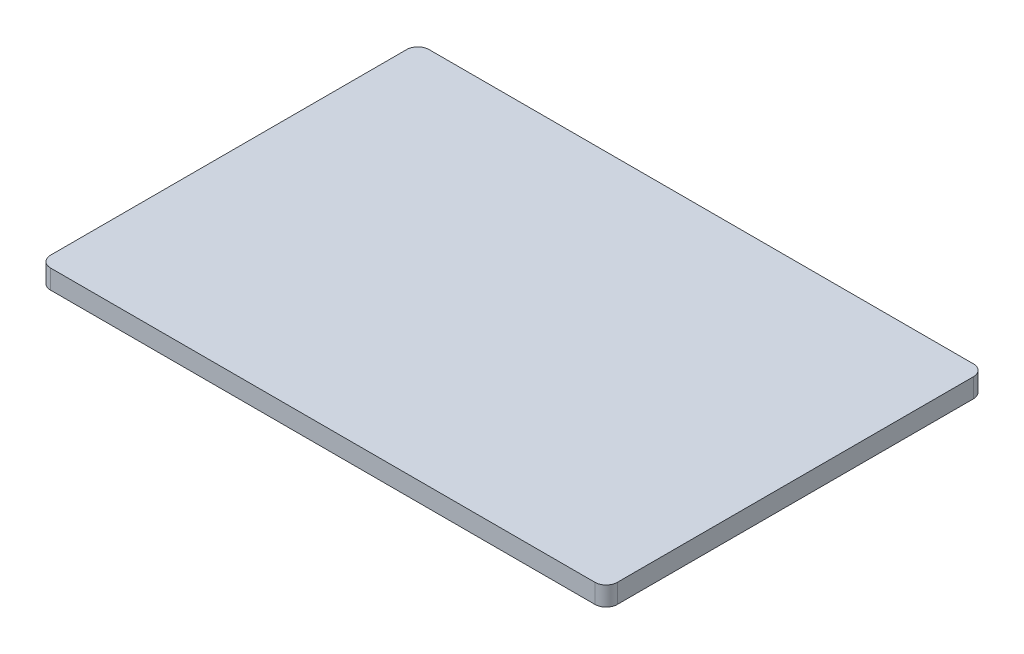
from build123d import *

# Parameters (mm, degrees)
SKETCH1_W           = 89.0392
SKETCH1_H           = 59.626
BOSS_EXTRUDE1_DEPTH = 2.9972
FILLET1_R           = 2
CUT_EXTRUDE1_DEPTH  = 3.9972


with BuildPart() as part:
    # Sketch1 → Boss-Extrude1 (new body)
    with BuildSketch(Plane(origin=(0, 0, 0), x_dir=(1, 0, 0), z_dir=(0, 1, 0))):
        Rectangle(SKETCH1_W, SKETCH1_H)
    extrude(amount=BOSS_EXTRUDE1_DEPTH)

    # Fillet1
    fillet1_edges = [part.edges().sort_by_distance(p)[0] for p in [
        (44.5196, 1.4986, 29.813),
        (-44.5196, 1.4986, 29.813),
        (-44.5196, 1.4986, -29.813),
        (44.5196, 1.4986, -29.813),
    ]]
    fillet(fillet1_edges, radius=FILLET1_R)

    # Sketch2 → Cut-Extrude1 (cut, through all)
    with BuildSketch(Plane(origin=(0, 2.9972, 0), x_dir=(1, 0, 0), z_dir=(0, 1, 0))):
        with BuildLine():
            ThreePointArc((-42.5196, 29.813), (-43.933813562, 29.227213562), (-44.5196, 27.813))
            Line((-44.5196, 27.813), (-44.5196, -27.813))
            ThreePointArc((-44.5196, -27.813), (-43.933813562, -29.227213562), (-42.5196, -29.813))
            Line((-42.5196, -29.813), (42.5196, -29.813))
            ThreePointArc((42.5196, -29.813), (43.933813562, -29.227213562), (44.5196, -27.813))
            Line((44.5196, -27.813), (44.5196, 27.813))
            ThreePointArc((44.5196, 27.813), (43.933813562, 29.227213562), (42.5196, 29.813))
            Line((42.5196, 29.813), (-42.5196, 29.813))
        make_face()
        with BuildLine():
            ThreePointArc((-42.5196, 29.559), (-43.75420844, 29.04760844), (-44.2656, 27.813))
            Line((-44.2656, 27.813), (-44.2656, -27.813))
            ThreePointArc((-44.2656, -27.813), (-43.75420844, -29.04760844), (-42.5196, -29.559))
            Line((-42.5196, -29.559), (42.5196, -29.559))
            ThreePointArc((42.5196, -29.559), (43.75420844, -29.04760844), (44.2656, -27.813))
            Line((44.2656, -27.813), (44.2656, 27.813))
            ThreePointArc((44.2656, 27.813), (43.75420844, 29.04760844), (42.5196, 29.559))
            Line((42.5196, 29.559), (-42.5196, 29.559))
        make_face(mode=Mode.SUBTRACT)
    extrude(amount=-CUT_EXTRUDE1_DEPTH, mode=Mode.SUBTRACT)


solid = part.part
